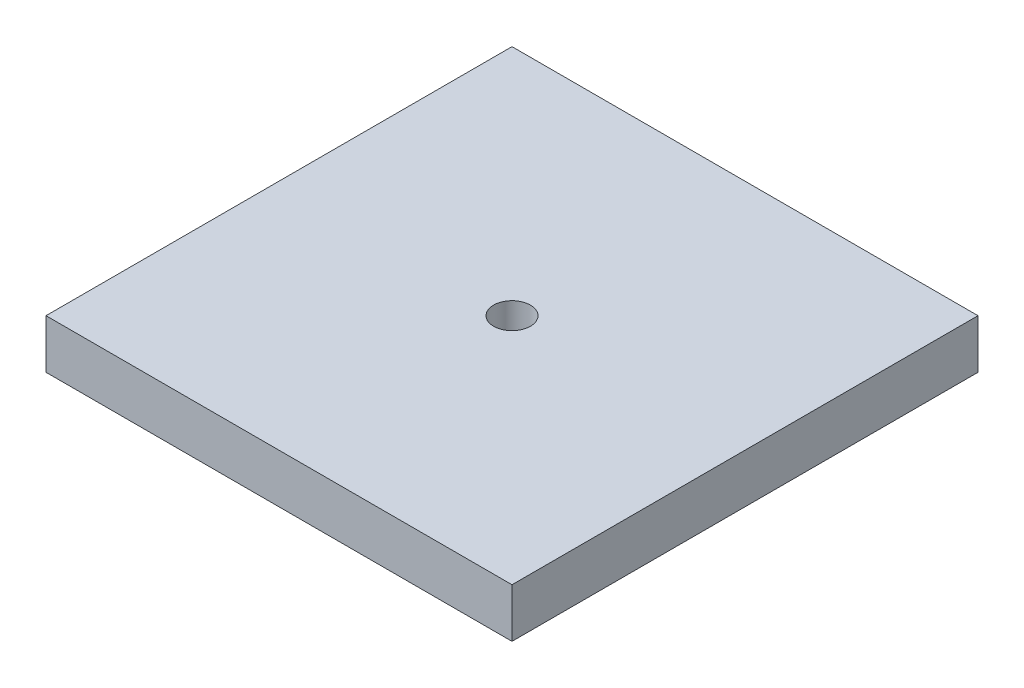
from build123d import *

# Parameters (mm, degrees)
SKETCH1_W           = 15.2
SKETCH1_H           = 15.2
BOSS_EXTRUDE1_DEPTH = 1.6
SKETCH2_R           = 0.6
CUT_EXTRUDE1_DEPTH  = 5


with BuildPart() as part:
    # Sketch1 → Boss-Extrude1 (new body)
    with BuildSketch(Plane(origin=(0, 0, 0), x_dir=(1, 0, 0), z_dir=(0, 1, 0))):
        with Locations((7.6, 7.6)):
            Rectangle(SKETCH1_W, SKETCH1_H)
    extrude(amount=BOSS_EXTRUDE1_DEPTH)

    # Sketch2 → Cut-Extrude1 (cut)
    with BuildSketch(Plane(origin=(0, 1.6, 0), x_dir=(1, 0, 0), z_dir=(0, 1, 0))):
        with Locations((7.6, 7.6)):
            Circle(SKETCH2_R)
    extrude(amount=-CUT_EXTRUDE1_DEPTH, mode=Mode.SUBTRACT)


solid = part.part
